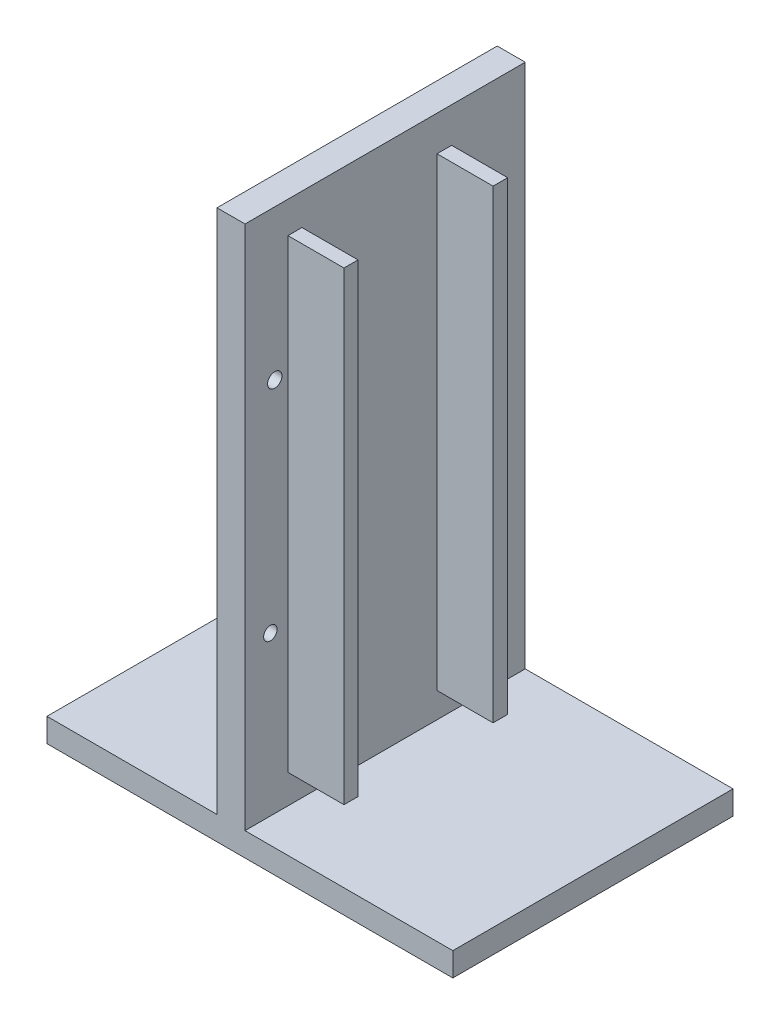
from build123d import *

# Parameters (mm, degrees)
SKETCH5_W           = 73.577123652
SKETCH5_H           = 99.547402554
BOSS_EXTRUDE2_DEPTH = 50.8
SKETCH6_W           = 30.82640112
SKETCH6_H           = 95.25
CUT_EXTRUDE3_DEPTH  = 50.8
SKETCH7_W           = 37.670722532
SKETCH7_H           = 95.25
CUT_EXTRUDE4_DEPTH  = 50.8
SKETCH8_W           = 2.54
SKETCH8_H           = 84.265204652
BOSS_EXTRUDE3_DEPTH = 10.16
SKETCH9_W           = 2.649849203
SKETCH9_H           = 84.265204652
BOSS_EXTRUDE4_DEPTH = 10.16
SKETCH10_R          = 1.3048994
CUT_EXTRUDE5_DEPTH  = 10.16
SKETCH11_R          = 1.324924601
CUT_EXTRUDE6_DEPTH  = 10.16
SKETCH12_R          = 1.221520127
CUT_EXTRUDE7_DEPTH  = 10.16
SKETCH13_R          = 1.364093366
CUT_EXTRUDE8_DEPTH  = 10.16


with BuildPart() as part:
    # Sketch5 → Boss-Extrude2 (new body)
    with BuildSketch(Plane.XY):
        with Locations((36.788561826, 49.773701277)):
            Rectangle(SKETCH5_W, SKETCH5_H)
    extrude(amount=BOSS_EXTRUDE2_DEPTH)

    # Sketch6 → Cut-Extrude3 (cut)
    with BuildSketch(Plane.XY.offset(50.8)):
        with Locations((15.41320056, 51.922402554)):
            Rectangle(SKETCH6_W, SKETCH6_H)
    extrude(amount=-CUT_EXTRUDE3_DEPTH, mode=Mode.SUBTRACT)

    # Sketch7 → Cut-Extrude4 (cut)
    with BuildSketch(Plane.XY.offset(50.8)):
        with Locations((54.741762386, 51.922402554)):
            Rectangle(SKETCH7_W, SKETCH7_H)
    extrude(amount=-CUT_EXTRUDE4_DEPTH, mode=Mode.SUBTRACT)

    # Sketch8 → Boss-Extrude3 (add)
    with BuildSketch(Plane(origin=(35.90640112, 0, 0), x_dir=(0, 0, -1), z_dir=(1, 0, 0))):
        with Locations((-41.751497199, 51.694841949)):
            Rectangle(SKETCH8_W, SKETCH8_H)
    extrude(amount=BOSS_EXTRUDE3_DEPTH)

    # Sketch9 → Boss-Extrude4 (add)
    with BuildSketch(Plane(origin=(35.90640112, 0, 0), x_dir=(0, 0, -1), z_dir=(1, 0, 0))):
        with Locations((-14.668110729, 51.032379648)):
            Rectangle(SKETCH9_W, SKETCH9_H)
    extrude(amount=BOSS_EXTRUDE4_DEPTH)

    # Sketch10 → Cut-Extrude5 (cut)
    with BuildSketch(Plane(origin=(35.90640112, 0, 0), x_dir=(0, 0, -1), z_dir=(1, 0, 0))):
        with Locations((-45.406361482, 72.363665732)):
            Circle(SKETCH10_R)
    extrude(amount=-CUT_EXTRUDE5_DEPTH, mode=Mode.SUBTRACT)

    # Sketch11 → Cut-Extrude6 (cut)
    with BuildSketch(Plane(origin=(35.90640112, 0, 0), x_dir=(0, 0, -1), z_dir=(1, 0, 0))):
        with Locations((-10.958321844, 73.158620492)):
            Circle(SKETCH11_R)
    extrude(amount=-CUT_EXTRUDE6_DEPTH, mode=Mode.SUBTRACT)

    # Sketch12 → Cut-Extrude7 (cut)
    with BuildSketch(Plane(origin=(35.90640112, 0, 0), x_dir=(0, 0, -1), z_dir=(1, 0, 0))):
        with Locations((-46.201316243, 33.013405069)):
            Circle(SKETCH12_R)
    extrude(amount=-CUT_EXTRUDE7_DEPTH, mode=Mode.SUBTRACT)

    # Sketch13 → Cut-Extrude8 (cut)
    with BuildSketch(Plane(origin=(35.90640112, 0, 0), x_dir=(0, 0, -1), z_dir=(1, 0, 0))):
        with Locations((-11.355799225, 30.893525706)):
            Circle(SKETCH13_R)
    extrude(amount=-CUT_EXTRUDE8_DEPTH, mode=Mode.SUBTRACT)


solid = part.part
